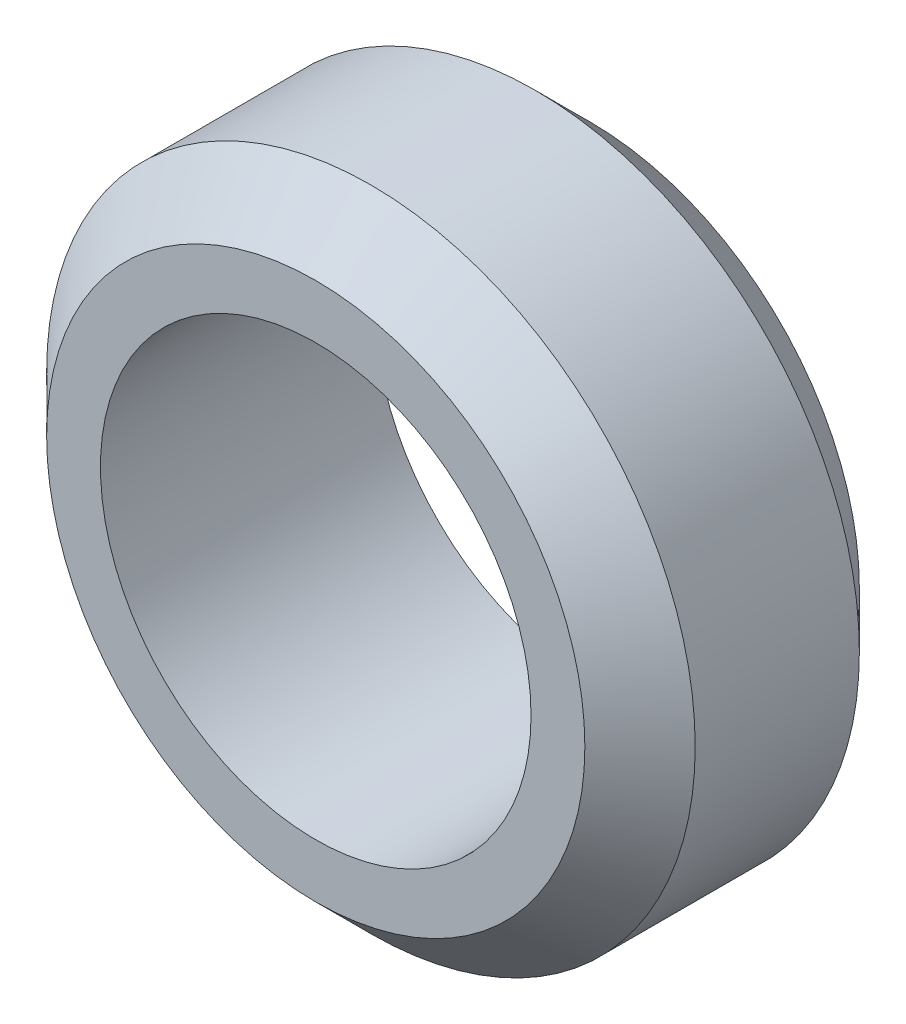
from build123d import *

# Parameters (mm, degrees)
SKETCH1_R           = 12.05
SKETCH1_R_2         = 8
BOSS_EXTRUDE1_DEPTH = 5.1
CHAMFER1_SIZE       = 2.05


with BuildPart() as part:
    # Sketch1 → Boss-Extrude1 (new body, symmetric)
    with BuildSketch(Plane.XY):
        Circle(SKETCH1_R)
        Circle(SKETCH1_R_2, mode=Mode.SUBTRACT)
    extrude(amount=BOSS_EXTRUDE1_DEPTH, both=True)

    # Chamfer1
    chamfer1_edges = [part.edges().sort_by_distance(p)[0] for p in [
        (-12.05, 0, -5.1),
        (-12.05, 0, 5.1),
    ]]
    chamfer(chamfer1_edges, length=CHAMFER1_SIZE)


solid = part.part
